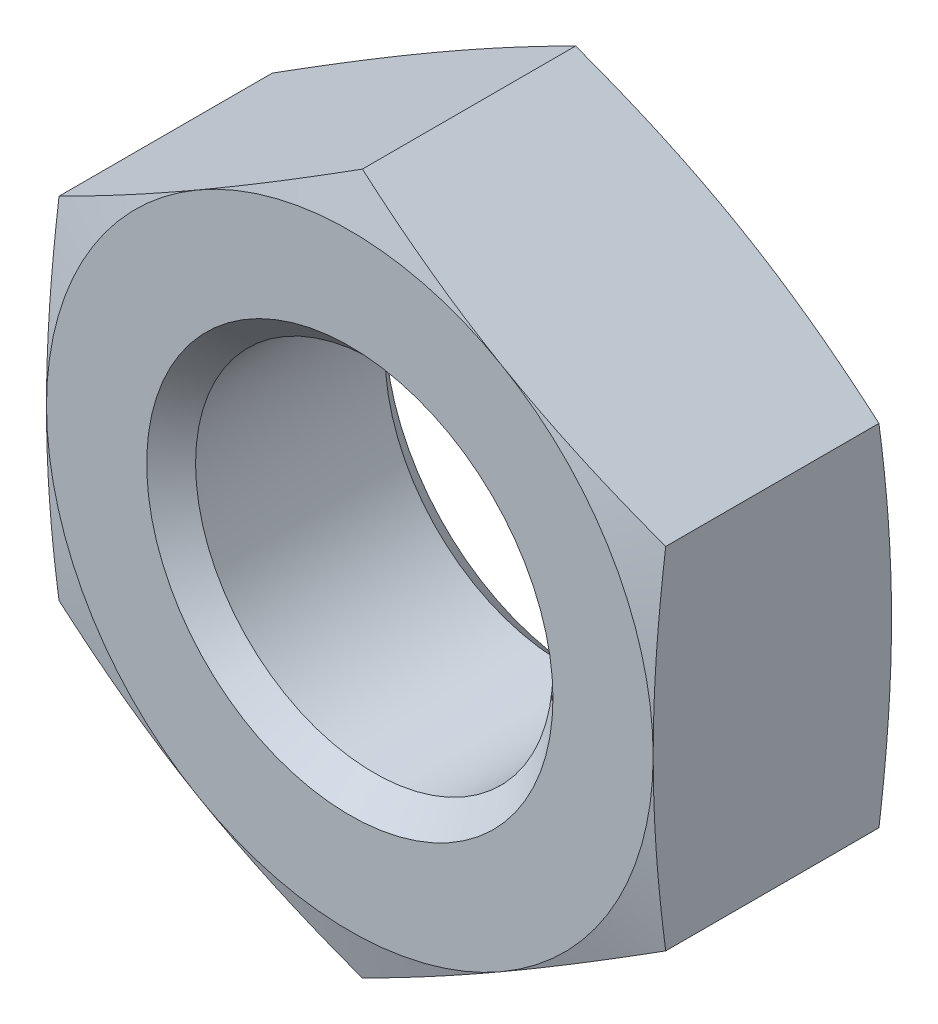
from build123d import *

# Parameters (mm, degrees)
SKETCH2_W          = 28.448
SKETCH2_H          = 28.448
CUT_EXTRUDE1_DEPTH = 5.588


with BuildPart() as part:
    # Sketch1 → Revolve1 (revolve)
    with BuildSketch(Plane(origin=(0, 0, 0), x_dir=(0, 0, -1), z_dir=(1, 0, 0))):
        Polygon((0, 0), (0, 7.112), (0.381130931, 8.5344), (5.206869069, 8.5344), (5.588, 7.112), (5.588, 0), align=None)
    revolve(axis=Axis((0, 0, -5.588), (0, 0, 1)))

    # Sketch2 → Cut-Extrude1 (cut)
    with BuildSketch(Plane.XY):
        Rectangle(SKETCH2_W, SKETCH2_H)
        Polygon((-7.112, 4.106115114), (-7.112, -4.106115114), (0, -8.212230229), (7.112, -4.106115114), (7.112, 4.106115114), (0, 8.212230229), align=None, mode=Mode.SUBTRACT)
    extrude(amount=-CUT_EXTRUDE1_DEPTH, mode=Mode.SUBTRACT)

    # Sketch3 → Cut-Revolve1 (revolve, cut)
    with BuildSketch(Plane(origin=(0, 0, 0), x_dir=(0, 0, -1), z_dir=(1, 0, 0))):
        Polygon((0, 0), (0, 4.7625), (0.57277, 4.18973), (5.01523, 4.18973), (5.588, 4.7625), (5.588, 0), align=None)
    revolve(axis=Axis((0, 0, -5.588), (0, 0, 1)), mode=Mode.SUBTRACT)


solid = part.part
